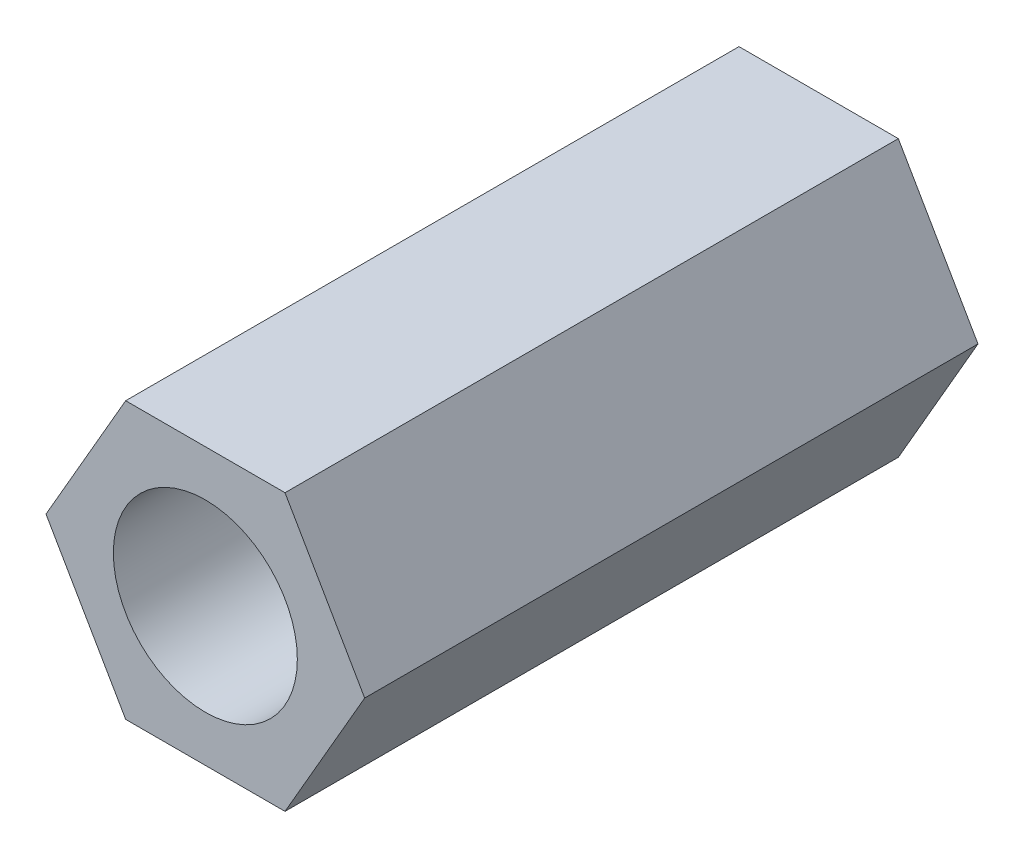
from build123d import *

# Parameters (mm, degrees)
ESQUISSE1_R        = 1.5
BOSS_EXTRU_1_DEPTH = 10


with BuildPart() as part:
    # Esquisse1 → Boss.-Extru.1 (new body)
    with BuildSketch(Plane.XY):
        Polygon((2.598076211, 0), (1.299038106, 2.25), (-1.299038106, 2.25), (-2.598076211, 0), (-1.299038106, -2.25), (1.299038106, -2.25), align=None)
        Circle(ESQUISSE1_R, mode=Mode.SUBTRACT)
    extrude(amount=BOSS_EXTRU_1_DEPTH)


solid = part.part
